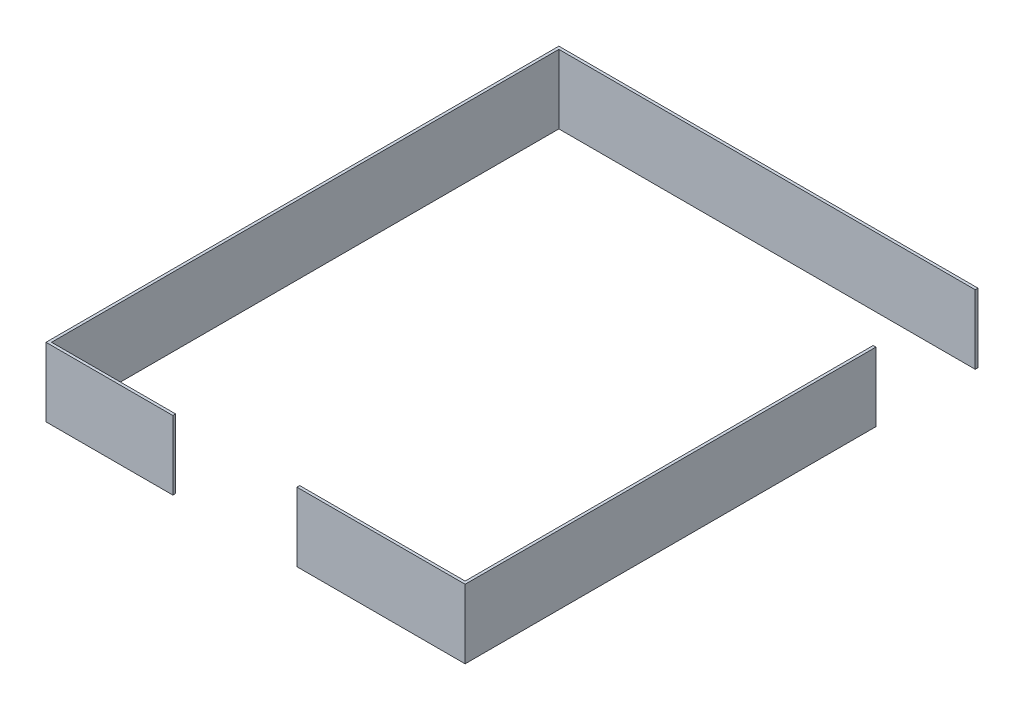
from build123d import *

# Parameters (mm, degrees)
SKETCH2_W           = 460
SKETCH2_H           = 10
BOSS_EXTRUDE2_DEPTH = 250
BOSS_EXTRUDE3_DEPTH = 250
BOSS_EXTRUDE4_DEPTH = 250
SKETCH2_14_W        = 10
SKETCH2_14_H        = 1480
BOSS_EXTRUDE5_DEPTH = 250
SKETCH2_15_W        = 1510
SKETCH2_15_H        = 10
BOSS_EXTRUDE6_DEPTH = 250


with BuildPart() as part:
    # Sketch2 → Boss-Extrude2 (new body)
    with BuildSketch(Plane(origin=(0, 0, 0), x_dir=(1, 0, 0), z_dir=(0, 1, 0))):
        with Locations((-680, -5)):
            Rectangle(SKETCH2_W, SKETCH2_H)
    extrude(amount=BOSS_EXTRUDE2_DEPTH)

    # Sketch2_11 → Boss-Extrude3 (add)
    with BuildSketch(Plane(origin=(0, 0, 0), x_dir=(1, 0, 0), z_dir=(0, 1, 0))):
        Polygon((-910, 1850), (-910, 0), (-900, 0), (-900, 1840), (-900, 1850), align=None)
    extrude(amount=BOSS_EXTRUDE3_DEPTH)

    # Sketch2_15 → Boss-Extrude6 (add)
    with BuildSketch(Plane(origin=(0, 0, 0), x_dir=(1, 0, 0), z_dir=(0, 1, 0))):
        with Locations((-145, 1845)):
            Rectangle(SKETCH2_15_W, SKETCH2_15_H)
    extrude(amount=BOSS_EXTRUDE6_DEPTH)


with BuildPart() as body_2:
    # Sketch2_12 → Boss-Extrude4 (new body)
    with BuildSketch(Plane(origin=(0, 0, 0), x_dir=(1, 0, 0), z_dir=(0, 1, 0))):
        Polygon((600, 0), (0, 0), (0, -10), (610, -10), (610, 0), align=None)
    extrude(amount=BOSS_EXTRUDE4_DEPTH)

    # Sketch2_14 → Boss-Extrude5 (add)
    with BuildSketch(Plane(origin=(0, 0, 0), x_dir=(1, 0, 0), z_dir=(0, 1, 0))):
        with Locations((605, 740)):
            Rectangle(SKETCH2_14_W, SKETCH2_14_H)
    extrude(amount=BOSS_EXTRUDE5_DEPTH)


solid = Compound([part.part, body_2.part])
